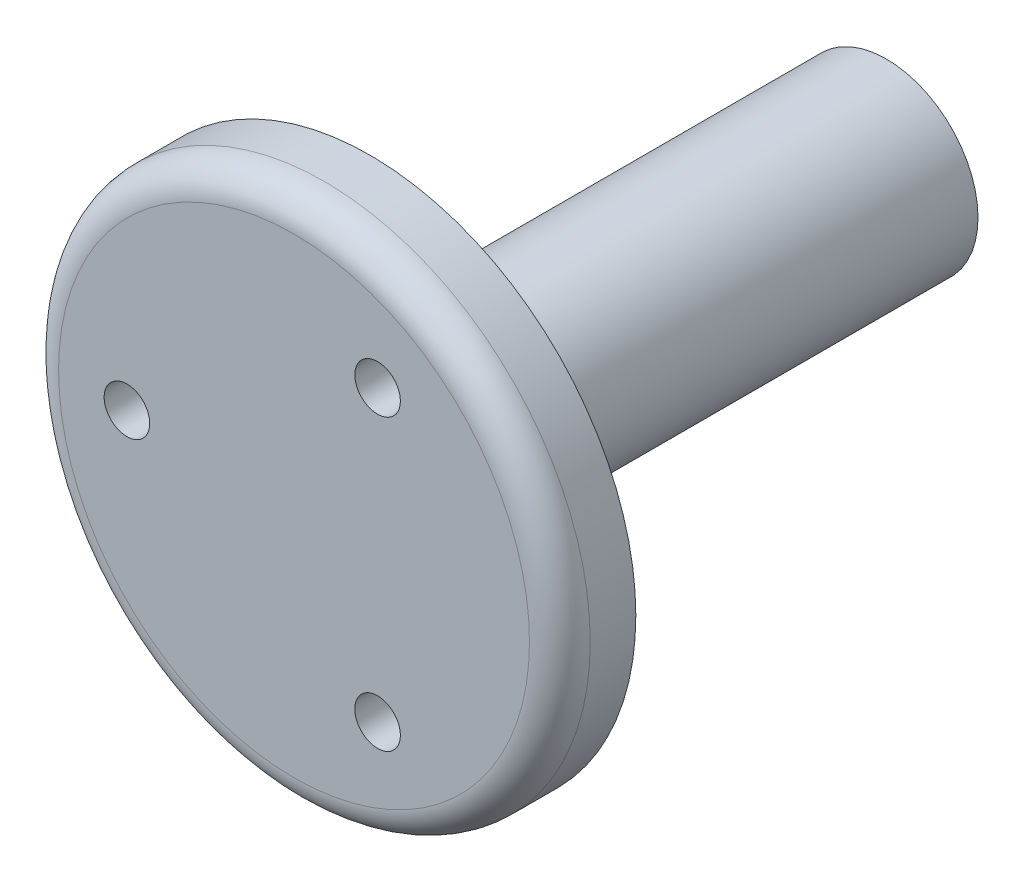
from build123d import *

# Parameters (mm, degrees)
ESQUISSE1_R             = 6.025
BOSS_EXTRU_1_DEPTH      = 34
ESQUISSE2_R             = 17.5
BOSS_EXTRU_2_DEPTH      = 5
ESQUISSE4_R             = 1.5
ENL_V_MAT_EXTRU_1_DEPTH = 10
CONG_1_R                = 2
ENL_V_MAT_EXTRU_2_DEPTH = 15
ESQUISSE6_R             = 1.5
ENL_V_MAT_EXTRU_3_DEPTH = 7


with BuildPart() as part:
    # Esquisse1 → Boss.-Extru.1 (new body)
    with BuildSketch(Plane.XY):
        Circle(ESQUISSE1_R)
    extrude(amount=BOSS_EXTRU_1_DEPTH)

    # Esquisse2 → Boss.-Extru.2 (add)
    with BuildSketch(Plane.XY.offset(34)):
        with Locations((0, 0.046797103)):
            Circle(ESQUISSE2_R)
    extrude(amount=BOSS_EXTRU_2_DEPTH)

    # Esquisse4 → Enlèv. mat.-Extru.1 (cut)
    with BuildSketch(Plane.XY.offset(39)):
        with Locations((-11, 0)):
            Circle(ESQUISSE4_R)
        with Locations((5.5, 9.526279442)):
            Circle(ESQUISSE4_R)
        with Locations((5.5, -9.526279442)):
            Circle(ESQUISSE4_R)
    extrude(amount=-ENL_V_MAT_EXTRU_1_DEPTH, mode=Mode.SUBTRACT)

    # Congé1
    cong_1_edges = [part.edges().sort_by_distance(p)[0] for p in [
        (-17.5, 0.046797103, 39),
    ]]
    fillet(cong_1_edges, radius=CONG_1_R)

    # Esquisse5 → Enlèv. mat.-Extru.2 (cut)
    with BuildSketch(Plane(origin=(0, 0, 0), x_dir=(-1, 0, 0), z_dir=(0, 0, -1))):
        with BuildLine():
            Line((1.525385197, -2.56), (-1.525385197, -2.56))
            ThreePointArc((-1.525385197, -2.56), (0, 2.978234065), (1.525385197, -2.56))
        make_face()
    extrude(amount=-ENL_V_MAT_EXTRU_2_DEPTH, mode=Mode.SUBTRACT)

    # Esquisse6 → Enlèv. mat.-Extru.3 (cut)
    with BuildSketch(Plane(origin=(0, 0, 0), x_dir=(1, 0, 0), z_dir=(0, 1, 0))):
        with Locations((0, -3)):
            Circle(ESQUISSE6_R)
    extrude(amount=-ENL_V_MAT_EXTRU_3_DEPTH, mode=Mode.SUBTRACT)


solid = part.part
